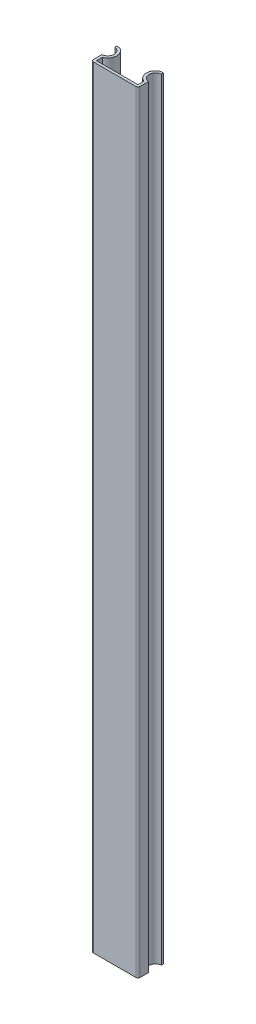
from build123d import *

# Parameters (mm, degrees)
EXTRUSION1_DEPTH = 182
CONG_1_R         = 0.5


with BuildPart() as part:
    # Esquisse1 → Extrusion1 (new body)
    with BuildSketch(Plane(origin=(0, 0, 0), x_dir=(1, 0, 0), z_dir=(0, 1, 0))):
        with BuildLine():
            Line((5.5, 0), (-5.5, 0))
            Line((-5.5, 0), (-5.5, 2.476845379))
            ThreePointArc((-5.5, 2.476845379), (-4.1, 4), (-5.5, 5.523154621))
            Line((-5.5, 5.523154621), (-5.5, 6))
            Line((-5.5, 6), (-4.9, 6))
            ThreePointArc((-4.9, 6), (-3.5, 4), (-4.9, 2))
            Line((-4.9, 2), (-4.9, 0.6))
            Line((-4.9, 0.6), (4.9, 0.6))
            Line((4.9, 0.6), (4.9, 2))
            ThreePointArc((4.9, 2), (3.5, 4), (4.9, 6))
            Line((4.9, 6), (5.5, 6))
            Line((5.5, 6), (5.5, 5.523154621))
            ThreePointArc((5.5, 5.523154621), (4.1, 4), (5.5, 2.476845379))
            Line((5.5, 2.476845379), (5.5, 0))
        make_face()
    extrude(amount=EXTRUSION1_DEPTH)

    # Congé1
    cong_1_edges = [part.edges().sort_by_distance(p)[0] for p in [
        (5.5, 91, 0),
        (-5.5, 91, 0),
    ]]
    fillet(cong_1_edges, radius=CONG_1_R)


solid = part.part
